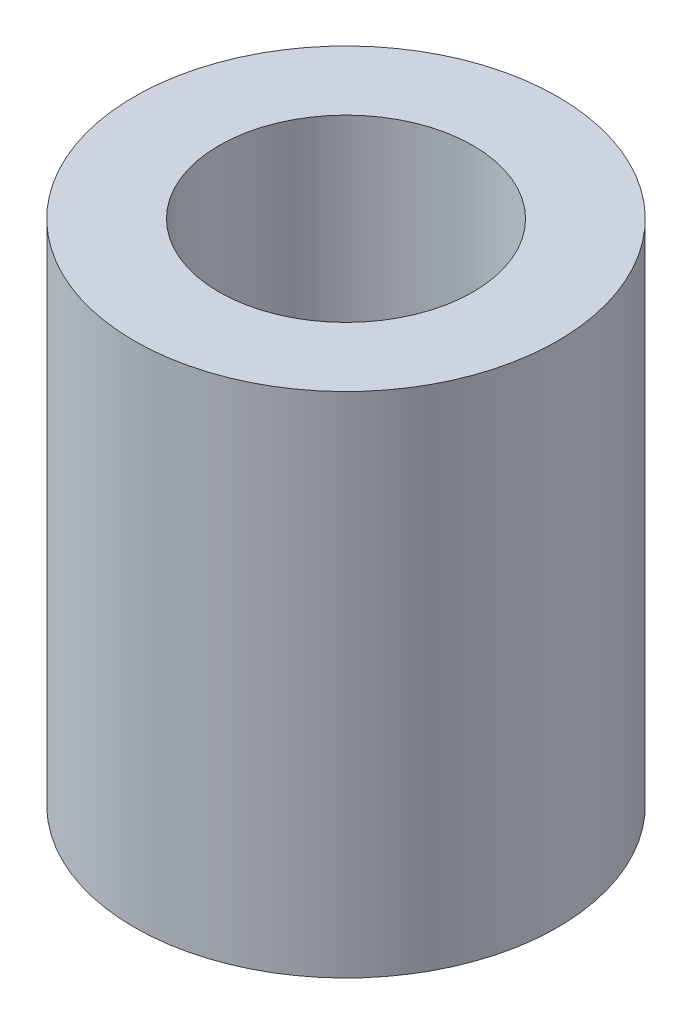
from build123d import *

# Parameters (mm, degrees)
SKETCH1_R           = 2.5
SKETCH1_R_2         = 1.5
BOSS_EXTRUDE1_DEPTH = 6


with BuildPart() as part:
    # Sketch1 → Boss-Extrude1 (new body)
    with BuildSketch(Plane(origin=(0, 0, 0), x_dir=(1, 0, 0), z_dir=(0, 1, 0))):
        Circle(SKETCH1_R)
        Circle(SKETCH1_R_2, mode=Mode.SUBTRACT)
    extrude(amount=BOSS_EXTRUDE1_DEPTH)


solid = part.part
